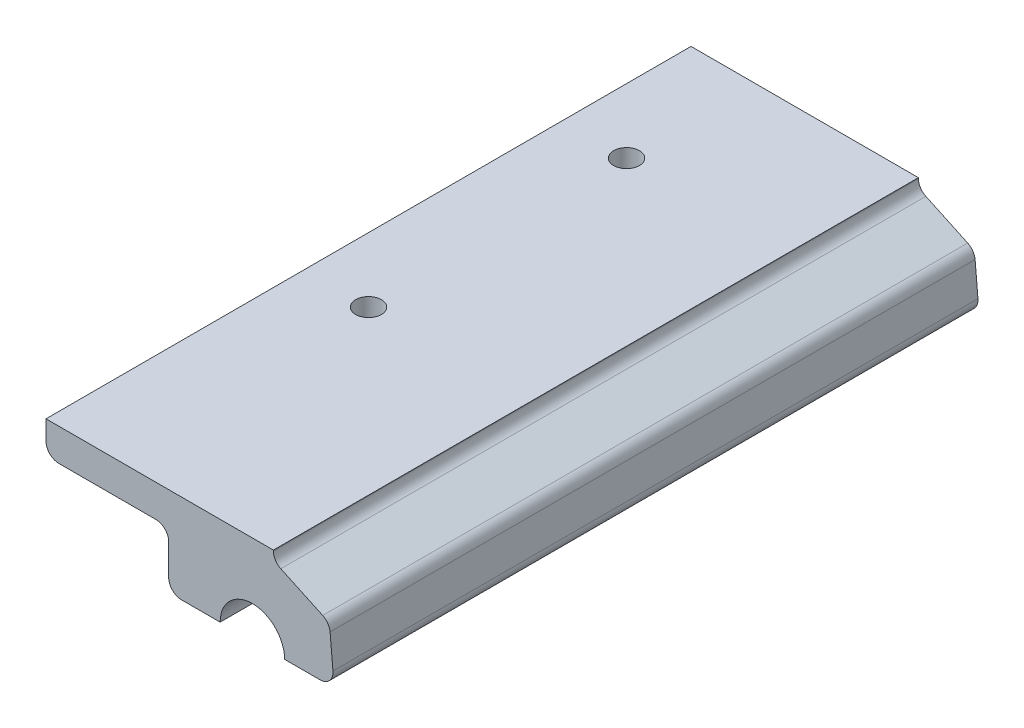
from build123d import *

# Parameters (mm, degrees)
SKETCH1_W            = 64.135
SKETCH1_H            = 127
BOSS_EXTRUDE1_DEPTH  = 6.35
BOSS_EXTRUDE13_DEPTH = 8.89
BOSS_EXTRUDE14_DEPTH = 8.5725
BOSS_EXTRUDE15_DEPTH = 6.985
BOSS_EXTRUDE16_DEPTH = 5.3975
BOSS_EXTRUDE17_START = 12.3825
BOSS_EXTRUDE17_DEPTH = 6.985
BOSS_EXTRUDE18_START = 27.94
BOSS_EXTRUDE18_DEPTH = 13.335
BOSS_EXTRUDE19_DEPTH = 27.94
BOSS_EXTRUDE20_START = 69.215
BOSS_EXTRUDE20_DEPTH = 13.97
BOSS_EXTRUDE21_START = 41.91
BOSS_EXTRUDE21_DEPTH = 28.575
BOSS_EXTRUDE22_START = 111.76
BOSS_EXTRUDE22_DEPTH = 6.35
SKETCH18_R           = 2.54
SKETCH18_W           = 19.3675
SKETCH18_H           = 127
CUT_EXTRUDE5_DEPTH   = 7.35
SKETCH20_W           = 1.905
SKETCH20_H           = 5.08
FILLET3_R            = 2.54


with BuildPart() as part:
    # Sketch1 → Boss-Extrude1 (new body)
    with BuildSketch(Plane(origin=(0, 0, 0), x_dir=(1, 0, 0), z_dir=(0, 1, 0))):
        Rectangle(SKETCH1_W, SKETCH1_H)
    extrude(amount=BOSS_EXTRUDE1_DEPTH)

    # Sketch12 → Boss-Extrude13 (add)
    with BuildSketch(Plane(origin=(0, 0, -63.5), x_dir=(-1, 0, 0), z_dir=(0, 0, -1))):
        Polygon((-37.660740352, -11.181831339), (-37.09962, -4.768196367), (-26.965439184, -0.042550244), (-17.805819185, -6.456185215), (-18.219259648, -11.181831339), (-11.455819185, -11.181831339), (-11.455819185, 6.35), (-28.281950999, 6.35), (-43.105928196, -0.562534091), (-44.03499632, -11.181831339), align=None)
    extrude(amount=-BOSS_EXTRUDE13_DEPTH)

    # Sketch13 → Boss-Extrude14 (add)
    with BuildSketch(Plane.XY.offset(-54.61)):
        with BuildLine():
            Line((44.03499632, -11.181831339), (34.29, -11.181831339))
            ThreePointArc((34.29, -11.181831339), (27.94, -4.831831339), (21.59, -11.181831339))
            Line((21.59, -11.181831339), (11.455819185, -11.181831339))
            Line((11.455819185, -11.181831339), (11.455819185, 0))
            Line((11.455819185, 0), (32.0675, 0))
            Line((32.0675, 0), (32.0675, 4.584769511))
            Line((32.0675, 4.584769511), (43.105928196, -0.562534091))
            Line((43.105928196, -0.562534091), (44.03499632, -11.181831339))
        make_face()
    extrude(amount=BOSS_EXTRUDE14_DEPTH)

    # Sketch14 → Boss-Extrude15 (add)
    with BuildSketch(Plane.XY.offset(-46.0375)):
        with BuildLine():
            Line((34.925, -11.181831339), (44.03499632, -11.181831339))
            Line((44.03499632, -11.181831339), (43.105928196, -0.562534091))
            Line((43.105928196, -0.562534091), (32.0675, 4.584769511))
            Line((32.0675, 4.584769511), (32.0675, 0))
            Line((32.0675, 0), (11.455819185, 0))
            Line((11.455819185, 0), (11.455819185, -11.181831339))
            Line((11.455819185, -11.181831339), (20.955, -11.181831339))
            ThreePointArc((20.955, -11.181831339), (27.94, -4.196831339), (34.925, -11.181831339))
        make_face()
    extrude(amount=BOSS_EXTRUDE15_DEPTH)

    # Sketch15 → Boss-Extrude16 (add)
    with BuildSketch(Plane.XY.offset(-39.0525)):
        with BuildLine():
            Line((36.03625, -11.181831339), (44.03499632, -11.181831339))
            Line((44.03499632, -11.181831339), (43.105928196, -0.562534091))
            Line((43.105928196, -0.562534091), (32.0675, 4.584769511))
            Line((32.0675, 4.584769511), (32.0675, 0))
            Line((32.0675, 0), (11.455819185, 0))
            Line((11.455819185, 0), (11.455819185, -11.181831339))
            Line((11.455819185, -11.181831339), (19.84375, -11.181831339))
            ThreePointArc((19.84375, -11.181831339), (27.94, -3.085581339), (36.03625, -11.181831339))
        make_face()
    extrude(amount=BOSS_EXTRUDE16_DEPTH)

    # Sketch14_2 → Boss-Extrude17 (add)
    with BuildSketch(Plane.XY.offset(-46.0375).offset(BOSS_EXTRUDE17_START)):
        with BuildLine():
            Line((34.925, -11.181831339), (44.03499632, -11.181831339))
            Line((44.03499632, -11.181831339), (43.105928196, -0.562534091))
            Line((43.105928196, -0.562534091), (32.0675, 4.584769511))
            Line((32.0675, 4.584769511), (32.0675, 0))
            Line((32.0675, 0), (11.455819185, 0))
            Line((11.455819185, 0), (11.455819185, -11.181831339))
            Line((11.455819185, -11.181831339), (20.955, -11.181831339))
            ThreePointArc((20.955, -11.181831339), (27.94, -4.196831339), (34.925, -11.181831339))
        make_face()
    extrude(amount=BOSS_EXTRUDE17_DEPTH)

    # Sketch13_2 → Boss-Extrude18 (add)
    with BuildSketch(Plane.XY.offset(-54.61).offset(BOSS_EXTRUDE18_START)):
        with BuildLine():
            Line((44.03499632, -11.181831339), (34.29, -11.181831339))
            ThreePointArc((34.29, -11.181831339), (27.94, -4.831831339), (21.59, -11.181831339))
            Line((21.59, -11.181831339), (11.455819185, -11.181831339))
            Line((11.455819185, -11.181831339), (11.455819185, 0))
            Line((11.455819185, 0), (32.0675, 0))
            Line((32.0675, 0), (32.0675, 4.584769511))
            Line((32.0675, 4.584769511), (43.105928196, -0.562534091))
            Line((43.105928196, -0.562534091), (44.03499632, -11.181831339))
        make_face()
    extrude(amount=BOSS_EXTRUDE18_DEPTH)

    # Sketch16 → Boss-Extrude19 (add)
    with BuildSketch(Plane.XY.offset(-13.335)):
        Polygon((20.6375, -11.181831339), (20.6375, -3.879331339), (35.2425, -3.879331339), (35.2425, -11.181831339), (44.03499632, -11.181831339), (43.105928196, -0.562534091), (32.0675, 4.584769511), (32.0675, 0), (11.455819185, 0), (11.455819185, -11.181831339), align=None)
    extrude(amount=BOSS_EXTRUDE19_DEPTH)

    # Sketch13_3 → Boss-Extrude20 (add)
    with BuildSketch(Plane.XY.offset(-54.61).offset(BOSS_EXTRUDE20_START)):
        with BuildLine():
            Line((44.03499632, -11.181831339), (34.29, -11.181831339))
            ThreePointArc((34.29, -11.181831339), (27.94, -4.831831339), (21.59, -11.181831339))
            Line((21.59, -11.181831339), (11.455819185, -11.181831339))
            Line((11.455819185, -11.181831339), (11.455819185, 0))
            Line((11.455819185, 0), (32.0675, 0))
            Line((32.0675, 0), (32.0675, 4.584769511))
            Line((32.0675, 4.584769511), (43.105928196, -0.562534091))
            Line((43.105928196, -0.562534091), (44.03499632, -11.181831339))
        make_face()
    extrude(amount=BOSS_EXTRUDE20_DEPTH)

    # Sketch16_2 → Boss-Extrude21 (add)
    with BuildSketch(Plane.XY.offset(-13.335).offset(BOSS_EXTRUDE21_START)):
        Polygon((20.6375, -11.181831339), (20.6375, -3.879331339), (35.2425, -3.879331339), (35.2425, -11.181831339), (44.03499632, -11.181831339), (43.105928196, -0.562534091), (32.0675, 4.584769511), (32.0675, 0), (11.455819185, 0), (11.455819185, -11.181831339), align=None)
    extrude(amount=BOSS_EXTRUDE21_DEPTH)

    # Sketch13_4 → Boss-Extrude22 (add)
    with BuildSketch(Plane.XY.offset(-54.61).offset(BOSS_EXTRUDE22_START)):
        with BuildLine():
            Line((44.03499632, -11.181831339), (34.29, -11.181831339))
            ThreePointArc((34.29, -11.181831339), (27.94, -4.831831339), (21.59, -11.181831339))
            Line((21.59, -11.181831339), (11.455819185, -11.181831339))
            Line((11.455819185, -11.181831339), (11.455819185, 0))
            Line((11.455819185, 0), (32.0675, 0))
            Line((32.0675, 0), (32.0675, 4.584769511))
            Line((32.0675, 4.584769511), (43.105928196, -0.562534091))
            Line((43.105928196, -0.562534091), (44.03499632, -11.181831339))
        make_face()
    extrude(amount=BOSS_EXTRUDE22_DEPTH)

    # Sketch18 → Cut-Extrude5 (cut, through all)
    with BuildSketch(Plane.XZ):
        with Locations((0, 12.7)):
            Circle(SKETCH18_R)
        with Locations((0, -38.1)):
            Circle(SKETCH18_R)
        with Locations((-22.38375, 0)):
            Rectangle(SKETCH18_W, SKETCH18_H)
    extrude(amount=-CUT_EXTRUDE5_DEPTH, mode=Mode.SUBTRACT)

    # Sketch20 → Cut-Revolve1 (revolve, cut)
    with BuildSketch(Plane.XZ.offset(11.181831339)):
        with Locations((16.522909592, -50.32375)):
            Rectangle(SKETCH20_W, SKETCH20_H)
        with Locations((16.522909592, 26.035)):
            Rectangle(SKETCH20_W, SKETCH20_H)
    revolve(axis=Axis((27.94, -11.181831339, 63.5), (0, 0, -1)), mode=Mode.SUBTRACT)

    # Fillet3
    fillet3_edges = [part.edges().sort_by_distance(p)[0] for p in [
        (11.455819185, 0, 0),
        (43.105928196, -0.562534091, 0),
        (44.03499632, -11.181831339, 0),
        (32.0675, 4.584769511, 0),
        (11.455819185, -11.181831339, 0),
        (-12.7, 0, 0),
    ]]
    fillet(fillet3_edges, radius=FILLET3_R)


solid = part.part
